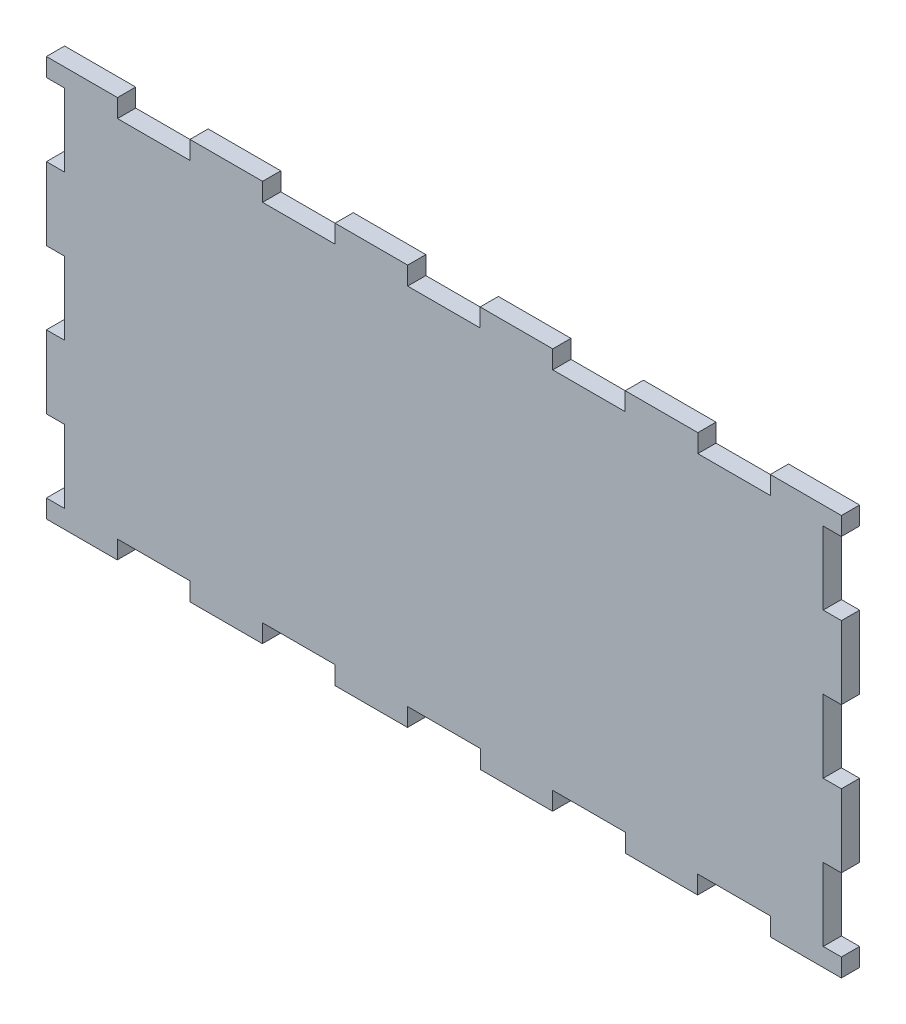
from build123d import *

# Parameters (mm, degrees)
BOSS_EXTRUDE1_DEPTH = 3
SKETCH3_W           = 3
SKETCH3_H           = 12
CUT_EXTRUDE1_DEPTH  = 6


with BuildPart() as part:
    # Sketch2 → Boss-Extrude1 (new body)
    with BuildSketch(Plane.XY):
        Polygon((-65.471428571, 3), (-53.786813187, 3), (-53.786813187, 6), (-41.786813187, 6), (-41.786813187, 3), (-29.879120879, 3), (-29.879120879, 6), (-17.879120879, 6), (-17.879120879, 3), (-5.971428571, 3), (-5.971428571, 6), (6.028571429, 6), (6.028571429, 3), (17.936263736, 3), (17.936263736, 6), (29.936263736, 6), (29.936263736, 3), (41.843956044, 3), (41.843956044, 6), (53.843956044, 6), (53.843956044, 3), (65.528571429, 3), (65.528571429, 69), (53.815384615, 69), (53.815384615, 66), (41.872527473, 66), (41.872527473, 69), (29.907692308, 69), (29.907692308, 66), (17.964835165, 66), (17.964835165, 69), (6, 69), (6, 66), (-5.942857143, 66), (-5.942857143, 69), (-17.907692308, 69), (-17.907692308, 66), (-29.850549451, 66), (-29.850549451, 69), (-41.815384615, 69), (-41.815384615, 66), (-53.758241758, 66), (-53.758241758, 69), (-65.471428571, 69), align=None)
    extrude(amount=BOSS_EXTRUDE1_DEPTH)

    # Sketch3 → Cut-Extrude1 (cut)
    with BuildSketch(Plane.XY.offset(3)):
        with Locations((-63.971428571, 60)):
            Rectangle(SKETCH3_W, SKETCH3_H)
        with Locations((-63.971428571, 12)):
            Rectangle(SKETCH3_W, SKETCH3_H)
        with Locations((64.028571429, 36)):
            Rectangle(SKETCH3_W, SKETCH3_H)
        with Locations((64.028571429, 12)):
            Rectangle(SKETCH3_W, SKETCH3_H)
        with Locations((-63.971428571, 36)):
            Rectangle(SKETCH3_W, SKETCH3_H)
        with Locations((64.028571429, 60)):
            Rectangle(SKETCH3_W, SKETCH3_H)
    extrude(amount=-CUT_EXTRUDE1_DEPTH, mode=Mode.SUBTRACT)


solid = part.part
